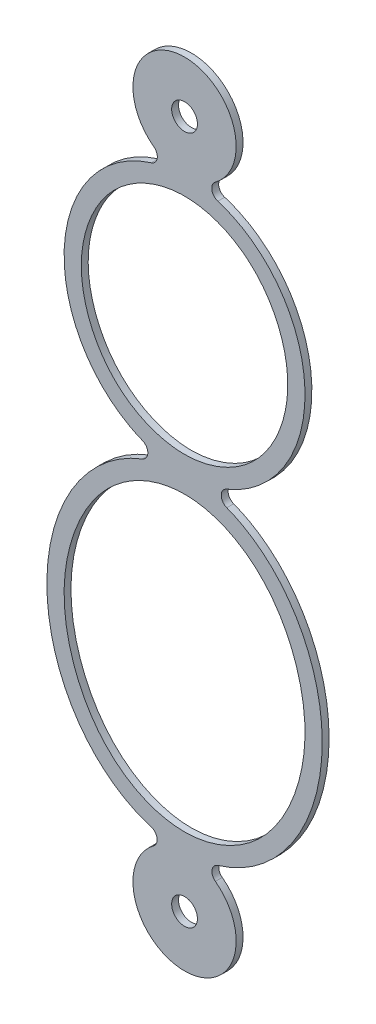
from build123d import *

# Parameters (mm, degrees)
SKETCH1_R           = 0.375
BOSS_EXTRUDE1_DEPTH = 0.1


with BuildPart() as part:
    # Sketch1 → Boss-Extrude1 (new, symmetric)
    with BuildSketch(Plane.XY):
        with BuildLine():
            ThreePointArc((0.891905879, 8.793971848), (0, 11.5), (-0.891905879, 8.793971848))
            ThreePointArc((-0.891905879, 8.793971848), (-0.794118372, 8.550918705), (-0.966968535, 8.354042987))
            add(Edge.make_bspline(
                [(-0.966968535, 8.354042987), (-11.16779536, 5.212201996), (-1.223571036, 1.236616962)],
                knots=[0.279917878, 0.279917878, 0.279917878, 2.784457357, 2.784457357, 2.784457357], degree=2, weights=[1, 0.313167604, 1]))
            ThreePointArc((-1.223571036, 1.236616962), (-1.066383194, 1.002630817), (-1.227016785, 0.770996659))
            add(Edge.make_bspline(
                [(-1.227016785, 0.770996659), (-14.522838837, -4.317608433), (-0.974024897, -8.357021838)],
                knots=[3.453373589, 3.453373589, 3.453373589, 6.037206048, 6.037206048, 6.037206048], degree=2, weights=[1, 0.275279187, 1]))
            ThreePointArc((-0.974024897, -8.357021838), (-0.799281912, -8.553011125), (-0.896102103, -8.797086445))
            ThreePointArc((-0.896102103, -8.797086445), (0, -11.5), (0.896102103, -8.797086445))
            ThreePointArc((0.896102103, -8.797086445), (0.799281912, -8.553011125), (0.974024897, -8.357021838))
            add(Edge.make_bspline(
                [(0.974024897, -8.357021838), (14.522838837, -4.317608433), (1.227016785, 0.770996659)],
                knots=[0.245979259, 0.245979259, 0.245979259, 2.829811718, 2.829811718, 2.829811718], degree=2, weights=[1, 0.275279187, 1]))
            ThreePointArc((1.227016785, 0.770996659), (1.066383194, 1.002630817), (1.223571036, 1.236616962))
            add(Edge.make_bspline(
                [(1.223571036, 1.236616962), (11.16779536, 5.212201996), (0.966968535, 8.354042987)],
                knots=[3.49872795, 3.49872795, 3.49872795, 6.003267429, 6.003267429, 6.003267429], degree=2, weights=[1, 0.313167604, 1]))
            ThreePointArc((0.966968535, 8.354042987), (0.794118372, 8.550918705), (0.891905879, 8.793971848))
        make_face()
        with Locations((0, 10)):
            Circle(SKETCH1_R, mode=Mode.SUBTRACT)
        with Locations((0, -10)):
            Circle(SKETCH1_R, mode=Mode.SUBTRACT)
        with BuildLine():
            add(Edge.make_bspline(
                [(0, 1.5), (0.7767692, 1.5), (2.3303076, 2.182014907), (3.3348462, 4.75), (2.3303076, 7.317985093), (0, 8.341007453), (-2.3303076, 7.317985093), (-3.3348462, 4.75), (-2.3303076, 2.182014907), (-0.7767692, 1.5), (0, 1.5)],
                knots=[0, 0, 0, 0, 0.785398163, 1.570796327, 2.35619449, 3.141592654, 3.926990817, 4.71238898, 5.497787144, 6.283185307, 6.283185307, 6.283185307, 6.283185307], degree=3))
        make_face(mode=Mode.SUBTRACT)
        with BuildLine():
            add(Edge.make_bspline(
                [(0, -8), (0.897698015, -8), (2.693094044, -7.134324579), (3.903452978, -3.75), (2.693094044, -0.365675421), (0, 0.932837711), (-2.693094044, -0.365675421), (-3.903452978, -3.75), (-2.693094044, -7.134324579), (-0.897698015, -8), (0, -8)],
                knots=[0, 0, 0, 0, 0.785398163, 1.570796327, 2.35619449, 3.141592654, 3.926990817, 4.71238898, 5.497787144, 6.283185307, 6.283185307, 6.283185307, 6.283185307], degree=3))
        make_face(mode=Mode.SUBTRACT)
    extrude(amount=BOSS_EXTRUDE1_DEPTH, both=True)


solid = part.part
